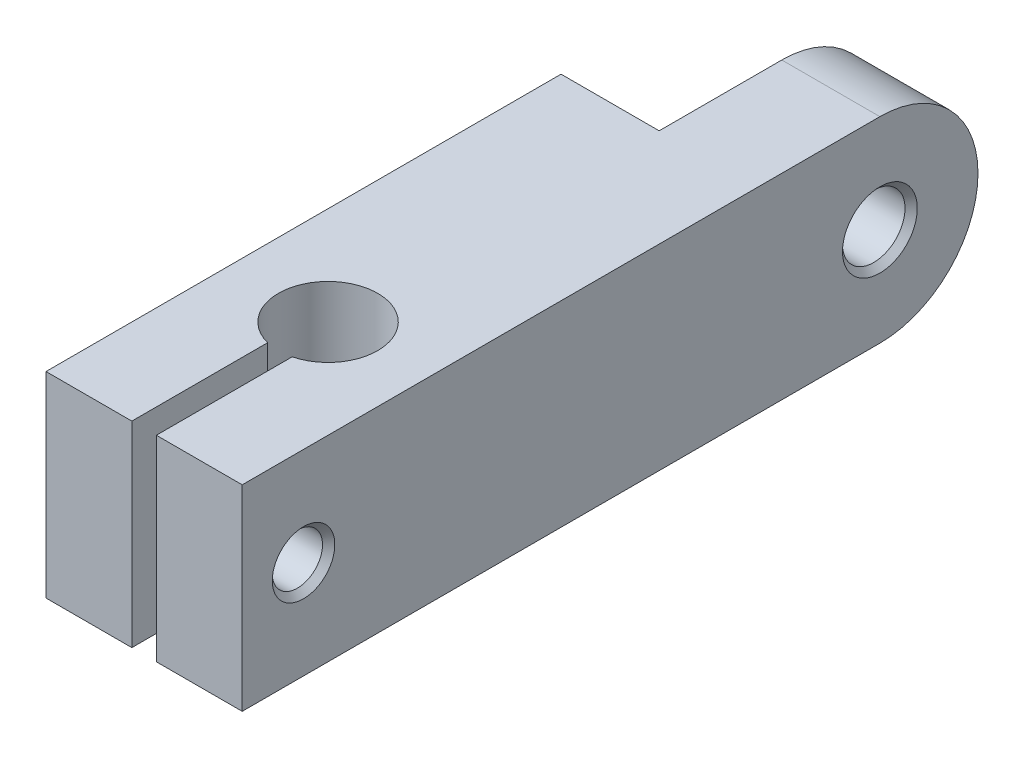
from build123d import *

# Parameters (mm, degrees)
SKETCH1_W                                   = 16
SKETCH1_H                                   = 16
BASE_DEPTH                                  = 60
INDICATORHOLE_DEPTH                         = 63.60990337
INDICATORMOUNT_REACH                        = 64.61
SKETCH3_R                                   = 2.05
CHAMFERINDICATORMOUNT_SIZE                  = 0.5
M4X0_7_TAPPED_HOLE_FOR_INDICATORSCREW_D     = 3.3
M4X0_7_TAPPED_HOLE_FOR_INDICATORSCREW_DEPTH = 7.908579979
M4X0_7_TAPPED_HOLE_FOR_INDICATORSCREW_TIP   = 0.991420021
SKETCH6_W                                   = 19.86895154
SKETCH6_H                                   = 16
SLOTFORANOTHERPART_DEPTH                    = 62.05735009
CHAMFERFORSLOT_DEPTH                        = 62.05735009
SKETCH7_R                                   = 2.55
SCREWHOLEFORSLOT_DEPTH                      = 63.60990337
CHAMFERFORSCREWSLOT_SIZE                    = 0.5


with BuildPart() as part:
    # Sketch1 → Base (new body)
    with BuildSketch(Plane.XY):
        Rectangle(SKETCH1_W, SKETCH1_H)
    extrude(amount=BASE_DEPTH)

    # Sketch2 → IndicatorHole (cut, through all)
    with BuildSketch(Plane(origin=(0, 8, 0), x_dir=(1, 0, 0), z_dir=(0, 1, 0))):
        with BuildLine():
            Line((-1, -48.924601891), (-1, -60))
            Line((-1, -60), (1, -60))
            Line((1, -60), (1, -48.924601891))
            ThreePointArc((1, -48.924601891), (0, -40.95), (-1, -48.924601891))
        make_face()
    extrude(amount=-INDICATORHOLE_DEPTH, mode=Mode.SUBTRACT)

    # Sketch3 → IndicatorMount (cut, up to next)
    with BuildSketch(Plane(origin=(8, 0, 0), x_dir=(0, 0, -1), z_dir=(1, 0, 0)), mode=Mode.PRIVATE) as indicatormount_sk1:
        with Locations((-55, 0)):
            Circle(SKETCH3_R)
    indicatormount_tool1 = extrude(indicatormount_sk1.sketch, amount=-INDICATORMOUNT_REACH, mode=Mode.PRIVATE) & part.part
    add(indicatormount_tool1.solids().sort_by_distance((8, 0, 55))[0], mode=Mode.SUBTRACT)

    # ChamferIndicatorMount
    chamferindicatormount_edges = [part.edges().sort_by_distance(p)[0] for p in [
        (8, 0, 57.05),
    ]]
    chamfer(chamferindicatormount_edges, length=CHAMFERINDICATORMOUNT_SIZE)

    # M4x0.7 Tapped Hole for IndicatorScrew
    with Locations(Plane.ZY.offset(8)):
        with Locations((55, 0)):
            Hole(M4X0_7_TAPPED_HOLE_FOR_INDICATORSCREW_D / 2, depth=M4X0_7_TAPPED_HOLE_FOR_INDICATORSCREW_DEPTH)
            with Locations((0, 0, -(M4X0_7_TAPPED_HOLE_FOR_INDICATORSCREW_DEPTH + M4X0_7_TAPPED_HOLE_FOR_INDICATORSCREW_TIP / 2))):  # 118° drill point
                Cone(0, M4X0_7_TAPPED_HOLE_FOR_INDICATORSCREW_D / 2, M4X0_7_TAPPED_HOLE_FOR_INDICATORSCREW_TIP, mode=Mode.SUBTRACT)

    # Sketch6 → SlotForAnotherPart (cut, through all)
    with BuildSketch(Plane(origin=(0, 0, 0), x_dir=(0, 0, -1), z_dir=(1, 0, 0))):
        with Locations((-8.06552423, 0)):
            Rectangle(SKETCH6_W, SKETCH6_H)
    extrude(amount=-SLOTFORANOTHERPART_DEPTH, mode=Mode.SUBTRACT)

    # Sketch6_3 → ChamferForSlot (cut, through all)
    with BuildSketch(Plane(origin=(0, 0, 0), x_dir=(0, 0, -1), z_dir=(1, 0, 0))):
        with BuildLine():
            Line((1.86895154, 8), (-8, 8))
            ThreePointArc((-8, 8), (-2.343145751, 5.656854249), (0, 0))
            ThreePointArc((0, 0), (-2.343145751, -5.656854249), (-8, -8))
            Line((-8, -8), (1.86895154, -8))
            Line((1.86895154, -8), (1.86895154, 8))
        make_face()
    extrude(amount=CHAMFERFORSLOT_DEPTH, mode=Mode.SUBTRACT)

    # Sketch7 → ScrewHoleForSlot (cut, through all)
    with BuildSketch(Plane(origin=(8, 0, 0), x_dir=(0, 0, -1), z_dir=(1, 0, 0))):
        with Locations((-8, 0)):
            Circle(SKETCH7_R)
    extrude(amount=-SCREWHOLEFORSLOT_DEPTH, mode=Mode.SUBTRACT)

    # ChamferForScrewSlot
    chamferforscrewslot_edges = [part.edges().sort_by_distance(p)[0] for p in [
        (8, 0, 10.55),
    ]]
    chamfer(chamferforscrewslot_edges, length=CHAMFERFORSCREWSLOT_SIZE)


solid = part.part
